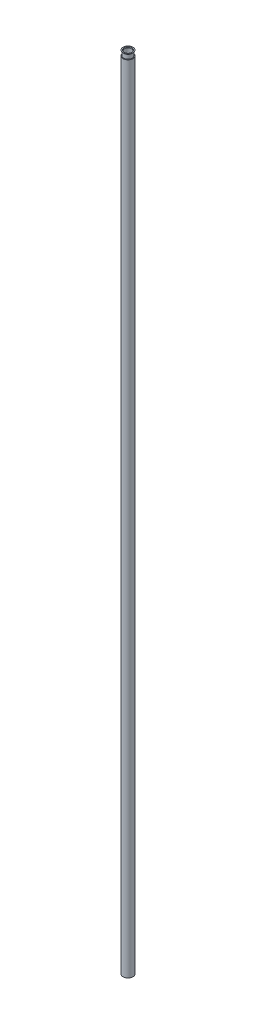
from build123d import *

# Parameters (mm, degrees)
CROQUIS1_R                 = 5
SALIENTE_EXTRUIR1_DEPTH    = 800
CROQUIS2_R                 = 3.5
CORTAR_EXTRUIR1_DEPTH      = 801
CROQUIS3_R                 = 6
SALIENTE_EXTRUIR2_DEPTH    = 1
CROQUIS4_R                 = 3.5
CORTAR_EXTRUIR3_DEPTH      = 1
CHAFL_N1_SIZE              = 1
CROQUIS5_W                 = 13.367882917
CROQUIS5_H                 = 1.687826657
CORTAR_EXTRUIR4_DEPTH      = 7
CORTAR_EXTRUIR4_DEPTH_BACK = 7


with BuildPart() as part:
    # Croquis1 → Saliente-Extruir1 (new body)
    with BuildSketch(Plane(origin=(0, 0, 0), x_dir=(1, 0, 0), z_dir=(0, 1, 0))):
        Circle(CROQUIS1_R)
    extrude(amount=SALIENTE_EXTRUIR1_DEPTH)

    # Croquis2 → Cortar-Extruir1 (cut, through all)
    with BuildSketch(Plane.XZ):
        Circle(CROQUIS2_R)
    extrude(amount=-CORTAR_EXTRUIR1_DEPTH, mode=Mode.SUBTRACT)

    # Croquis3 → Saliente-Extruir2 (add)
    with BuildSketch(Plane(origin=(0, 800, 0), x_dir=(1, 0, 0), z_dir=(0, 1, 0))):
        Circle(CROQUIS3_R)
    extrude(amount=SALIENTE_EXTRUIR2_DEPTH)

    # Croquis4 → Cortar-Extruir3 (cut)
    with BuildSketch(Plane(origin=(0, 801, 0), x_dir=(1, 0, 0), z_dir=(0, 1, 0))):
        Circle(CROQUIS4_R)
    extrude(amount=-CORTAR_EXTRUIR3_DEPTH, mode=Mode.SUBTRACT)

    # Chaflán1
    chafl_n1_edges = [part.edges().sort_by_distance(p)[0] for p in [
        (-3.5, 801, 0),
    ]]
    chamfer(chafl_n1_edges, length=CHAFL_N1_SIZE)

    # Croquis5 → Cortar-Extruir4 (cut, two sides)
    with BuildSketch(Plane.XY) as cortar_extruir4_sk:
        with Locations((0.334446828, 800.843913329)):
            Rectangle(CROQUIS5_W, CROQUIS5_H)
    extrude(amount=CORTAR_EXTRUIR4_DEPTH, mode=Mode.SUBTRACT)
    extrude(cortar_extruir4_sk.sketch, amount=-CORTAR_EXTRUIR4_DEPTH_BACK, mode=Mode.SUBTRACT)

    # Croquis6 → Revolución1 (revolve)
    with BuildSketch(Plane.XY):
        Polygon((-3.5, 800), (-3.5, 804.5), (-4, 805), (-5, 805), (-4.26, 804.25), (-4.26, 800), align=None)
    revolve(axis=Axis((0, 810.031166981, 0), (0, -1, 0)))


solid = part.part
